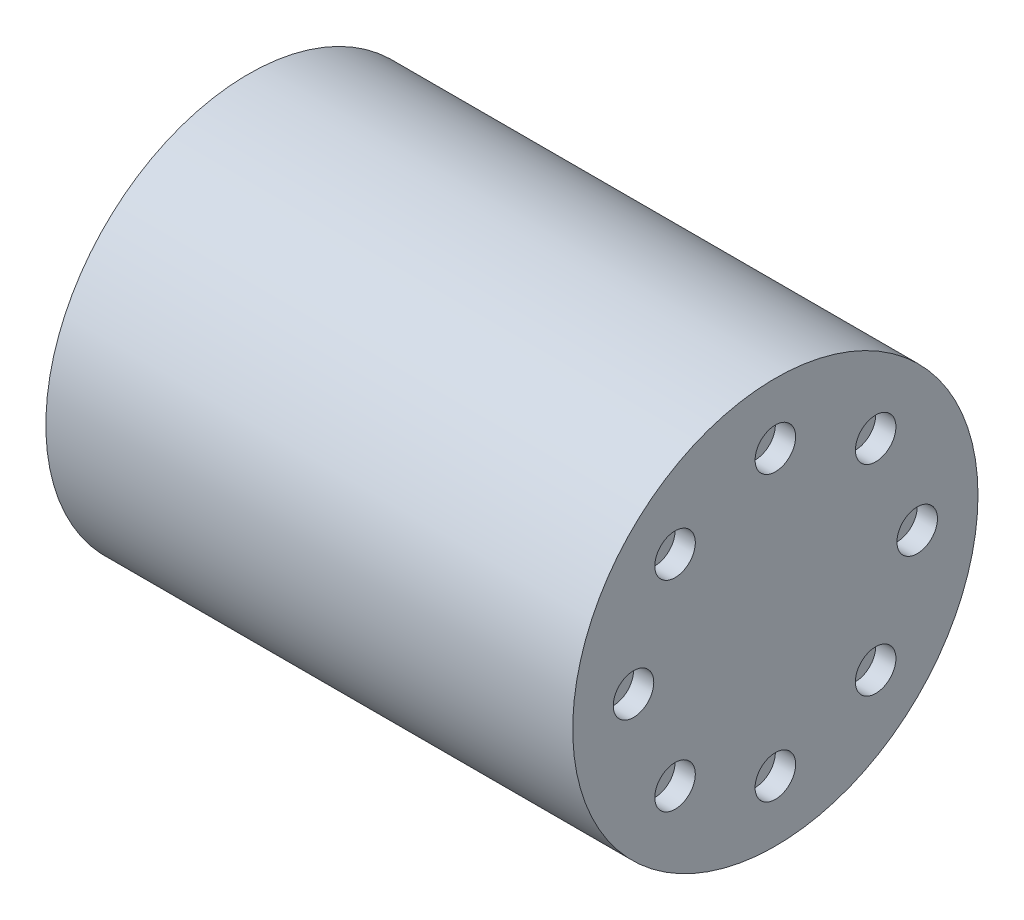
from build123d import *

# Parameters (mm, degrees)
SKETCH1_R           = 50
BOSS_EXTRUDE1_DEPTH = 65
SKETCH2_R           = 4
BOSS_EXTRUDE2_DEPTH = 12
SKETCH3_R           = 5
CUT_EXTRUDE1_DEPTH  = 5
CIRPATTERN1_COUNT   = 8
SKETCH4_R           = 5
CUT_EXTRUDE2_DEPTH  = 5
CIRPATTERN2_COUNT   = 8


with BuildPart() as part:
    # Sketch1 → Boss-Extrude1 (new body, symmetric)
    with BuildSketch(Plane(origin=(0, 0, 0), x_dir=(0, 0, -1), z_dir=(1, 0, 0))):
        Circle(SKETCH1_R)
    extrude(amount=BOSS_EXTRUDE1_DEPTH, both=True)

    # Sketch2 → Boss-Extrude2 (add)
    with BuildSketch(Plane.ZY.offset(65)):
        Circle(SKETCH2_R)
    extrude(amount=BOSS_EXTRUDE2_DEPTH)

    # Sketch3 → Cut-Extrude1 (cut)
    with BuildSketch(Plane.ZY.offset(65)):
        with Locations((0, 35)):
            Circle(SKETCH3_R)
    cut_extrude1 = extrude(amount=-CUT_EXTRUDE1_DEPTH, mode=Mode.SUBTRACT)

    # CirPattern1: Cut-Extrude1 ×8 about axis
    cirpattern1_axis = Axis((0, 0, 0), (1, 0, 0))
    for i in range(1, CIRPATTERN1_COUNT):
        add(cut_extrude1.rotate(cirpattern1_axis, i * 360 / CIRPATTERN1_COUNT), mode=Mode.SUBTRACT)

    # Sketch4 → Cut-Extrude2 (cut)
    with BuildSketch(Plane(origin=(65, 0, 0), x_dir=(0, 0, -1), z_dir=(1, 0, 0))):
        with Locations((0, 35)):
            Circle(SKETCH4_R)
    cut_extrude2 = extrude(amount=-CUT_EXTRUDE2_DEPTH, mode=Mode.SUBTRACT)

    # CirPattern2: Cut-Extrude2 ×8 about axis
    cirpattern2_axis = Axis((0, 0, 0), (1, 0, 0))
    for i in range(1, CIRPATTERN2_COUNT):
        add(cut_extrude2.rotate(cirpattern2_axis, i * 360 / CIRPATTERN2_COUNT), mode=Mode.SUBTRACT)


solid = part.part
